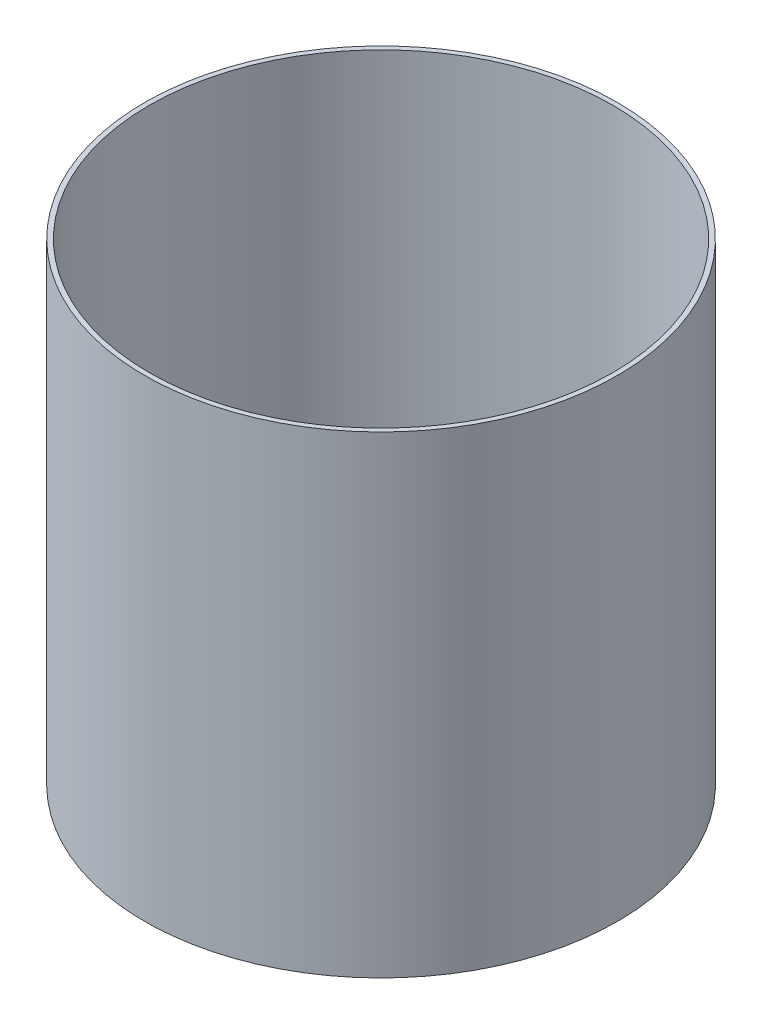
from build123d import *

# Parameters (mm, degrees)
CROQUIS1_W = 250
CROQUIS1_H = 500
VACIADO1_T = -5


with BuildPart() as part:
    # Croquis1 → Revolución1 (revolve)
    with BuildSketch(Plane.XY, mode=Mode.PRIVATE) as revoluci_n1_sk:
        with Locations((-125, 250)):
            Rectangle(CROQUIS1_W, CROQUIS1_H)
    revolve(revoluci_n1_sk.sketch.rotate(Axis((0, 0, 0), (0, 1, 0)), 270), axis=Axis((0, 0, 0), (0, 1, 0)))  # turned: the seam where the file's is

    # Vaciado1
    vaciado1_openings = [part.faces().sort_by_distance(p)[0] for p in [
        (0, 500, 0),
        (0, 0, 0),
    ]]
    offset(amount=VACIADO1_T, openings=vaciado1_openings, kind=Kind.INTERSECTION)


solid = part.part
